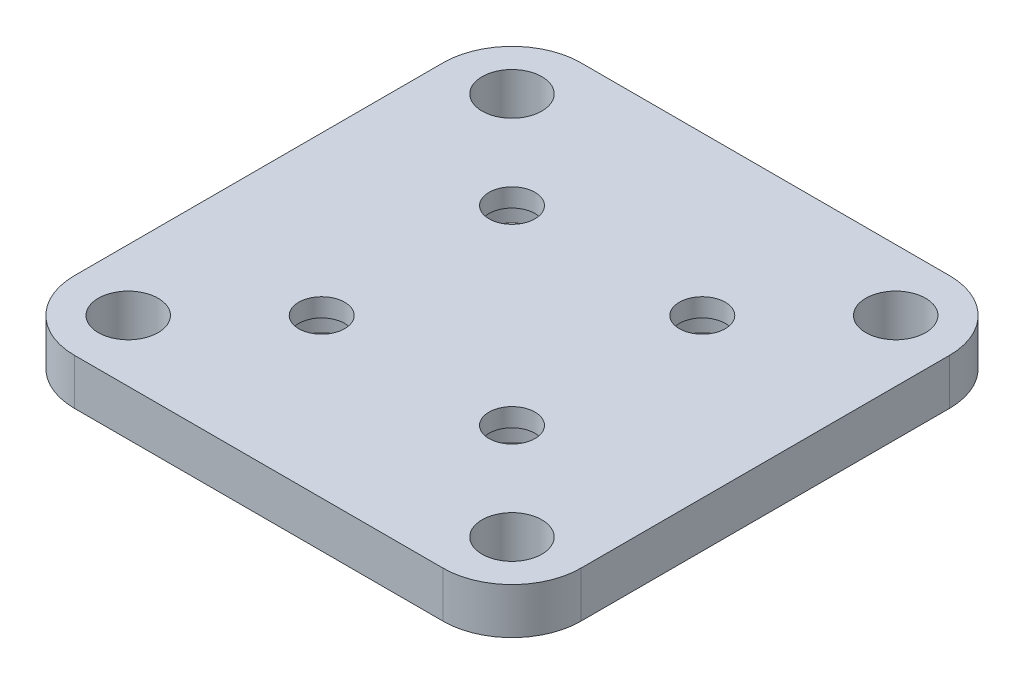
from build123d import *

# Parameters (mm, degrees)
SKETCH1_W           = 55.1
SKETCH1_H           = 55.1
BOSS_EXTRUDE1_DEPTH = 5
FILLET1_R           = 7.5
SKETCH2_R           = 3.25
CUT_EXTRUDE1_DEPTH  = 6
SKETCH3_R           = 2.5
CUT_EXTRUDE2_DEPTH  = 5
SKETCH4_R           = 4.75
CUT_EXTRUDE3_DEPTH  = 3


with BuildPart() as part:
    # Sketch1 → Boss-Extrude1 (new body)
    with BuildSketch(Plane(origin=(0, 0, 0), x_dir=(1, 0, 0), z_dir=(0, 1, 0))):
        Rectangle(SKETCH1_W, SKETCH1_H)
    extrude(amount=BOSS_EXTRUDE1_DEPTH)

    # Fillet1
    fillet1_edges = [part.edges().sort_by_distance(p)[0] for p in [
        (27.55, 2.5, 27.55),
        (-27.55, 2.5, 27.55),
        (-27.55, 2.5, -27.55),
        (27.55, 2.5, -27.55),
    ]]
    fillet(fillet1_edges, radius=FILLET1_R)

    # Sketch2 → Cut-Extrude1 (cut, through all)
    with BuildSketch(Plane(origin=(0, 5, 0), x_dir=(1, 0, 0), z_dir=(0, 1, 0))):
        with Locations((-20.874050615, 20.870277104)):
            Circle(SKETCH2_R)
        with Locations((-20.874050615, -20.869722896)):
            Circle(SKETCH2_R)
        with Locations((20.865949385, 20.870277104)):
            Circle(SKETCH2_R)
        with Locations((20.865949385, -20.869722896)):
            Circle(SKETCH2_R)
    extrude(amount=-CUT_EXTRUDE1_DEPTH, mode=Mode.SUBTRACT)

    # Sketch3 → Cut-Extrude2 (cut)
    with BuildSketch(Plane(origin=(0, 5, 0), x_dir=(1, 0, 0), z_dir=(0, 1, 0))):
        with Locations((-10.35, 10.35)):
            Circle(SKETCH3_R)
        with Locations((10.35, 10.35)):
            Circle(SKETCH3_R)
        with Locations((-10.35, -10.35)):
            Circle(SKETCH3_R)
        with Locations((10.35, -10.35)):
            Circle(SKETCH3_R)
    extrude(amount=-CUT_EXTRUDE2_DEPTH, mode=Mode.SUBTRACT)

    # Sketch4 → Cut-Extrude3 (cut)
    with BuildSketch(Plane.XZ):
        with Locations((-10.35, 10.35)):
            Circle(SKETCH4_R)
        with Locations((10.35, 10.35)):
            Circle(SKETCH4_R)
        with Locations((10.35, -10.35)):
            Circle(SKETCH4_R)
        with Locations((-10.35, -10.35)):
            Circle(SKETCH4_R)
    extrude(amount=-CUT_EXTRUDE3_DEPTH, mode=Mode.SUBTRACT)


solid = part.part
